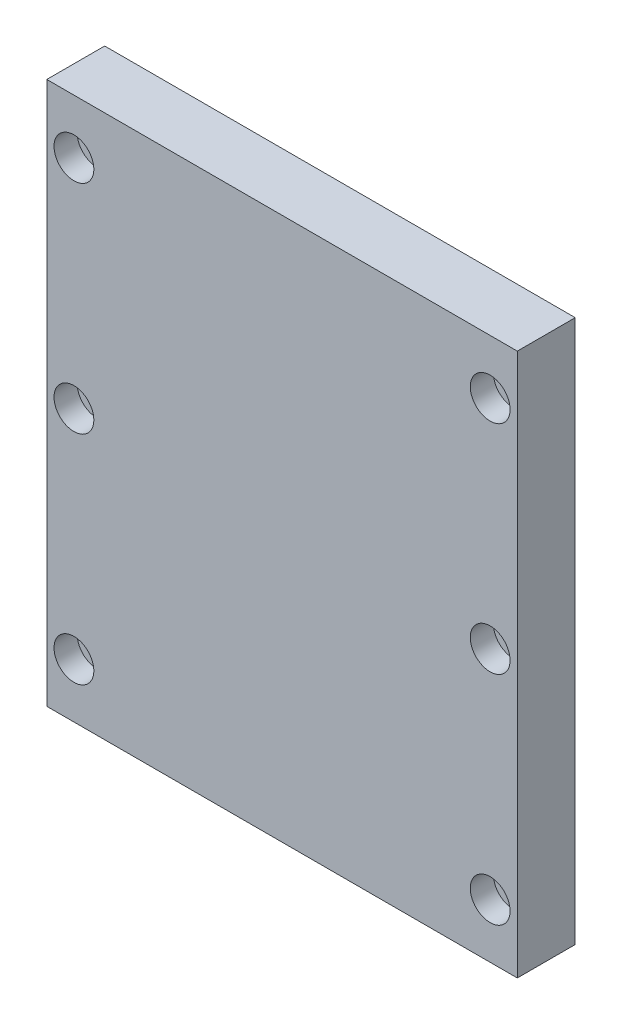
from build123d import *

# Parameters (mm, degrees)
SKETCH1_W                                           = 130
SKETCH1_H                                           = 150
EXTRUDE1_DEPTH                                      = 16
CBORE_FOR_M6_HEX_SOCKET_HEAD_CAP_SCREW1_D           = 6.6
CBORE_FOR_M6_HEX_SOCKET_HEAD_CAP_SCREW1_CBORE_D     = 11
CBORE_FOR_M6_HEX_SOCKET_HEAD_CAP_SCREW1_CBORE_DEPTH = 6.4


with BuildPart() as part:
    # Sketch1 → Extrude1 (new body)
    with BuildSketch(Plane.XY):
        Rectangle(SKETCH1_W, SKETCH1_H)
    extrude(amount=EXTRUDE1_DEPTH)

    # CBORE for M6 Hex Socket Head Cap Screw1 (through all)
    with Locations(Plane.XY.offset(16)):
        with Locations((-57.5, 60), (-57.5, 0), (-57.5, -60), (57.5, -60), (57.5, 0), (57.5, 60)):
            CounterBoreHole(CBORE_FOR_M6_HEX_SOCKET_HEAD_CAP_SCREW1_D / 2, CBORE_FOR_M6_HEX_SOCKET_HEAD_CAP_SCREW1_CBORE_D / 2, CBORE_FOR_M6_HEX_SOCKET_HEAD_CAP_SCREW1_CBORE_DEPTH)


solid = part.part
